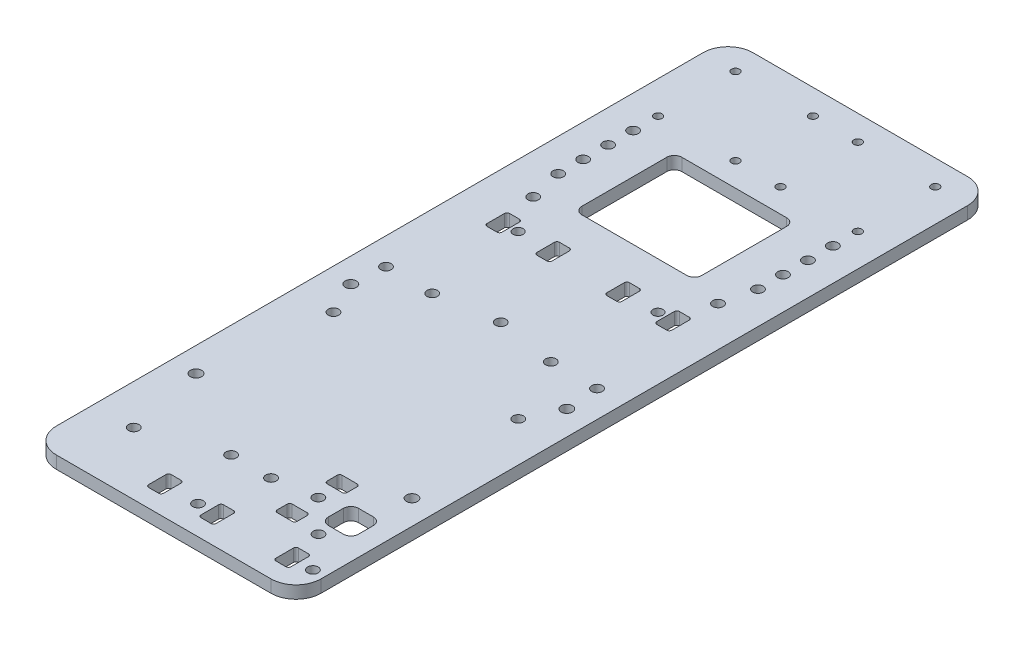
from build123d import *

# Parameters (mm, degrees)
SKETCH_1_R          = 1.6
SKETCH_1_R_2        = 2.1
SKETCH_1_R_3        = 2
EXTRUDE_1_DEPTH     = 5
SKETCH_2_R          = 2.25
CUT_EXTRUDE_2_DEPTH = 10
SKETCH_3_R          = 2.1
CUT_EXTRUDE_3_DEPTH = 27
CUT_EXTRUDE_4_DEPTH = 20
SKETCH_5_R          = 2.1
CUT_EXTRUDE_5_DEPTH = 20


with BuildPart() as part:
    # 草图1 → 凸台-拉伸1 (new body)
    with BuildSketch(Plane(origin=(0, 0, 0), x_dir=(1, 0, 0), z_dir=(0, 1, 0))):
        with BuildLine():
            Line((-43, -137), (43, -137))
            ThreePointArc((43, -137), (50.071067812, -134.071067812), (53, -127))
            Line((53, -127), (53, 132))
            ThreePointArc((53, 132), (50.071067812, 139.071067812), (43, 142))
            Line((43, 142), (-43, 142))
            ThreePointArc((-43, 142), (-50.071067812, 139.071067812), (-53, 132))
            Line((-53, 132), (-53, -127))
            ThreePointArc((-53, -127), (-50.071067812, -134.071067812), (-43, -137))
        make_face()
        with Locations((-40, 132)):
            Circle(SKETCH_1_R, mode=Mode.SUBTRACT)
        with Locations((-9, 132)):
            Circle(SKETCH_1_R, mode=Mode.SUBTRACT)
        with Locations((-9, 101)):
            Circle(SKETCH_1_R, mode=Mode.SUBTRACT)
        with Locations((-40, 101)):
            Circle(SKETCH_1_R, mode=Mode.SUBTRACT)
        with Locations((9, 101)):
            Circle(SKETCH_1_R, mode=Mode.SUBTRACT)
        with Locations((40, 101)):
            Circle(SKETCH_1_R, mode=Mode.SUBTRACT)
        with Locations((9, 132)):
            Circle(SKETCH_1_R, mode=Mode.SUBTRACT)
        with Locations((40, 132)):
            Circle(SKETCH_1_R, mode=Mode.SUBTRACT)
        with Locations((-37, -112)):
            Circle(SKETCH_1_R_2, mode=Mode.SUBTRACT)
        with Locations((-37, -32)):
            Circle(SKETCH_1_R_2, mode=Mode.SUBTRACT)
        with Locations((-37, 48)):
            Circle(SKETCH_1_R_2, mode=Mode.SUBTRACT)
        with Locations((37, -112)):
            Circle(SKETCH_1_R_2, mode=Mode.SUBTRACT)
        with Locations((37, -32)):
            Circle(SKETCH_1_R_2, mode=Mode.SUBTRACT)
        with Locations((37, 48)):
            Circle(SKETCH_1_R_2, mode=Mode.SUBTRACT)
        with Locations((-40, 91)):
            Circle(SKETCH_1_R_2, mode=Mode.SUBTRACT)
        with Locations((-40, 81)):
            Circle(SKETCH_1_R_2, mode=Mode.SUBTRACT)
        with Locations((-40, 71)):
            Circle(SKETCH_1_R_2, mode=Mode.SUBTRACT)
        with Locations((-40, 61)):
            Circle(SKETCH_1_R_2, mode=Mode.SUBTRACT)
        with Locations((40, 61)):
            Circle(SKETCH_1_R_2, mode=Mode.SUBTRACT)
        with Locations((40, 71)):
            Circle(SKETCH_1_R_2, mode=Mode.SUBTRACT)
        with Locations((40, 81)):
            Circle(SKETCH_1_R_2, mode=Mode.SUBTRACT)
        with Locations((40, 91)):
            Circle(SKETCH_1_R_2, mode=Mode.SUBTRACT)
        with Locations((-42.25, -5.7)):
            Circle(SKETCH_1_R_2, mode=Mode.SUBTRACT)
        with Locations((-23.75, -5.7)):
            Circle(SKETCH_1_R_2, mode=Mode.SUBTRACT)
        with Locations((23.75, -5.7)):
            Circle(SKETCH_1_R_2, mode=Mode.SUBTRACT)
        with Locations((42.25, -5.7)):
            Circle(SKETCH_1_R_2, mode=Mode.SUBTRACT)
        with Locations((-28, 32.95)):
            Circle(SKETCH_1_R_3, mode=Mode.SUBTRACT)
        with Locations((28, 32.95)):
            Circle(SKETCH_1_R_3, mode=Mode.SUBTRACT)
        with BuildLine():
            Line((21, 91.5), (-21, 91.5))
            ThreePointArc((-21, 91.5), (-23.121320344, 90.621320344), (-24, 88.5))
            Line((-24, 88.5), (-24, 54.5))
            ThreePointArc((-24, 54.5), (-23.121320344, 52.378679656), (-21, 51.5))
            Line((-21, 51.5), (21, 51.5))
            ThreePointArc((21, 51.5), (23.121320344, 52.378679656), (24, 54.5))
            Line((24, 54.5), (24, 88.5))
            ThreePointArc((24, 88.5), (23.121320344, 90.621320344), (21, 91.5))
        make_face(mode=Mode.SUBTRACT)
        with BuildLine():
            Line((-36, 37.5), (-32, 37.5))
            ThreePointArc((-32, 37.5), (-31.292893219, 37.207106781), (-31, 36.5))
            Line((-31, 36.5), (-31, 29.5))
            ThreePointArc((-31, 29.5), (-31.292893219, 28.792893219), (-32, 28.5))
            Line((-32, 28.5), (-36, 28.5))
            ThreePointArc((-36, 28.5), (-36.707106781, 28.792893219), (-37, 29.5))
            Line((-37, 29.5), (-37, 36.5))
            ThreePointArc((-37, 36.5), (-36.707106781, 37.207106781), (-36, 37.5))
        make_face(mode=Mode.SUBTRACT)
        with BuildLine():
            Line((-16, 37.5), (-12, 37.5))
            ThreePointArc((-12, 37.5), (-11.292893219, 37.207106781), (-11, 36.5))
            Line((-11, 36.5), (-11, 29.5))
            ThreePointArc((-11, 29.5), (-11.292893219, 28.792893219), (-12, 28.5))
            Line((-12, 28.5), (-16, 28.5))
            ThreePointArc((-16, 28.5), (-16.707106781, 28.792893219), (-17, 29.5))
            Line((-17, 29.5), (-17, 36.5))
            ThreePointArc((-17, 36.5), (-16.707106781, 37.207106781), (-16, 37.5))
        make_face(mode=Mode.SUBTRACT)
        with BuildLine():
            Line((37, 36.5), (37, 29.5))
            ThreePointArc((37, 29.5), (36.707106781, 28.792893219), (36, 28.5))
            Line((36, 28.5), (32, 28.5))
            ThreePointArc((32, 28.5), (31.292893219, 28.792893219), (31, 29.5))
            Line((31, 29.5), (31, 36.5))
            ThreePointArc((31, 36.5), (31.292893219, 37.207106781), (32, 37.5))
            Line((32, 37.5), (36, 37.5))
            ThreePointArc((36, 37.5), (36.707106781, 37.207106781), (37, 36.5))
        make_face(mode=Mode.SUBTRACT)
        with BuildLine():
            Line((17, 36.5), (17, 29.5))
            ThreePointArc((17, 29.5), (16.707106781, 28.792893219), (16, 28.5))
            Line((16, 28.5), (12, 28.5))
            ThreePointArc((12, 28.5), (11.292893219, 28.792893219), (11, 29.5))
            Line((11, 29.5), (11, 36.5))
            ThreePointArc((11, 36.5), (11.292893219, 37.207106781), (12, 37.5))
            Line((12, 37.5), (16, 37.5))
            ThreePointArc((16, 37.5), (16.707106781, 37.207106781), (17, 36.5))
        make_face(mode=Mode.SUBTRACT)
    extrude(amount=EXTRUDE_1_DEPTH)

    # 草图2 → 切除-拉伸2 (cut)
    with BuildSketch(Plane(origin=(0, 0, 0), x_dir=(1, 0, 0), z_dir=(0, 1, 0))):
        with Locations((-43.25, -80.8)):
            Circle(SKETCH_2_R)
        with Locations((43.25, -80.8)):
            Circle(SKETCH_2_R)
        with Locations((-43.25, -18.8)):
            Circle(SKETCH_2_R)
        with Locations((43.25, -18.8)):
            Circle(SKETCH_2_R)
    extrude(amount=CUT_EXTRUDE_2_DEPTH, mode=Mode.SUBTRACT)

    # 草图3 → 切除-拉伸3 (cut)
    with BuildSketch(Plane(origin=(0, 0, 0), x_dir=(1, 0, 0), z_dir=(0, 1, 0))):
        with Locations((2.28, -125.5)):
            Circle(SKETCH_3_R)
        with Locations((48.28, -125.5)):
            Circle(SKETCH_3_R)
        with Locations((24.28, -99.327742623)):
            Circle(SKETCH_3_R)
        with BuildLine():
            Line((37.78, -120.8), (41.78, -120.8))
            ThreePointArc((41.78, -120.8), (42.487106781, -121.092893219), (42.78, -121.8))
            Line((42.78, -121.8), (42.78, -128.8))
            ThreePointArc((42.78, -128.8), (42.487106781, -129.507106781), (41.78, -129.8))
            Line((41.78, -129.8), (37.78, -129.8))
            ThreePointArc((37.78, -129.8), (37.072893219, -129.507106781), (36.78, -128.8))
            Line((36.78, -128.8), (36.78, -121.8))
            ThreePointArc((36.78, -121.8), (37.072893219, -121.092893219), (37.78, -120.8))
        make_face()
        with BuildLine():
            Line((7.78, -120.8), (11.78, -120.8))
            ThreePointArc((11.78, -120.8), (12.487106781, -121.092893219), (12.78, -121.8))
            Line((12.78, -121.8), (12.78, -128.8))
            ThreePointArc((12.78, -128.8), (12.487106781, -129.507106781), (11.78, -129.8))
            Line((11.78, -129.8), (7.78, -129.8))
            ThreePointArc((7.78, -129.8), (7.072893219, -129.507106781), (6.78, -128.8))
            Line((6.78, -128.8), (6.78, -121.8))
            ThreePointArc((6.78, -121.8), (7.072893219, -121.092893219), (7.78, -120.8))
        make_face()
        with BuildLine():
            Line((21.28, -106.8), (27.28, -106.8))
            ThreePointArc((27.28, -106.8), (27.987106781, -107.092893219), (28.28, -107.8))
            Line((28.28, -107.8), (28.28, -111.8))
            ThreePointArc((28.28, -111.8), (27.987106781, -112.507106781), (27.28, -112.8))
            Line((27.28, -112.8), (21.28, -112.8))
            ThreePointArc((21.28, -112.8), (20.572893219, -112.507106781), (20.28, -111.8))
            Line((20.28, -111.8), (20.28, -107.8))
            ThreePointArc((20.28, -107.8), (20.572893219, -107.092893219), (21.28, -106.8))
        make_face()
        with BuildLine():
            Line((21.28, -86.8), (27.28, -86.8))
            ThreePointArc((27.28, -86.8), (27.987106781, -87.092893219), (28.28, -87.8))
            Line((28.28, -87.8), (28.28, -91.8))
            ThreePointArc((28.28, -91.8), (27.987106781, -92.507106781), (27.28, -92.8))
            Line((27.28, -92.8), (21.28, -92.8))
            ThreePointArc((21.28, -92.8), (20.572893219, -92.507106781), (20.28, -91.8))
            Line((20.28, -91.8), (20.28, -87.8))
            ThreePointArc((20.28, -87.8), (20.572893219, -87.092893219), (21.28, -86.8))
        make_face()
        with BuildLine():
            Line((-8.22, -121.8), (-8.22, -128.8))
            ThreePointArc((-8.22, -128.8), (-8.512893219, -129.507106781), (-9.22, -129.8))
            Line((-9.22, -129.8), (-13.22, -129.8))
            ThreePointArc((-13.22, -129.8), (-13.927106781, -129.507106781), (-14.22, -128.8))
            Line((-14.22, -128.8), (-14.22, -121.8))
            ThreePointArc((-14.22, -121.8), (-13.927106781, -121.092893219), (-13.22, -120.8))
            Line((-13.22, -120.8), (-9.22, -120.8))
            ThreePointArc((-9.22, -120.8), (-8.512893219, -121.092893219), (-8.22, -121.8))
        make_face()
    extrude(amount=CUT_EXTRUDE_3_DEPTH, mode=Mode.SUBTRACT)

    # 草图4 → 切除-拉伸4 (cut)
    with BuildSketch(Plane(origin=(0, 0, 0), x_dir=(1, 0, 0), z_dir=(0, 1, 0))):
        with BuildLine():
            Line((36, -95), (42, -95))
            ThreePointArc((42, -95), (44.121320344, -95.878679656), (45, -98))
            Line((45, -98), (45, -104))
            ThreePointArc((45, -104), (44.121320344, -106.121320344), (42, -107))
            Line((42, -107), (36, -107))
            ThreePointArc((36, -107), (33.878679656, -106.121320344), (33, -104))
            Line((33, -104), (33, -98))
            ThreePointArc((33, -98), (33.878679656, -95.878679656), (36, -95))
        make_face()
    extrude(amount=CUT_EXTRUDE_4_DEPTH, mode=Mode.SUBTRACT)

    # 草图5 → 切除-拉伸5 (cut)
    with BuildSketch(Plane(origin=(0, 0, 0), x_dir=(1, 0, 0), z_dir=(0, 1, 0))):
        with Locations((0, -2)):
            Circle(SKETCH_5_R)
        with Locations((-8, -102)):
            Circle(SKETCH_5_R)
        with Locations((8, -102)):
            Circle(SKETCH_5_R)
    extrude(amount=CUT_EXTRUDE_5_DEPTH, mode=Mode.SUBTRACT)


solid = part.part
